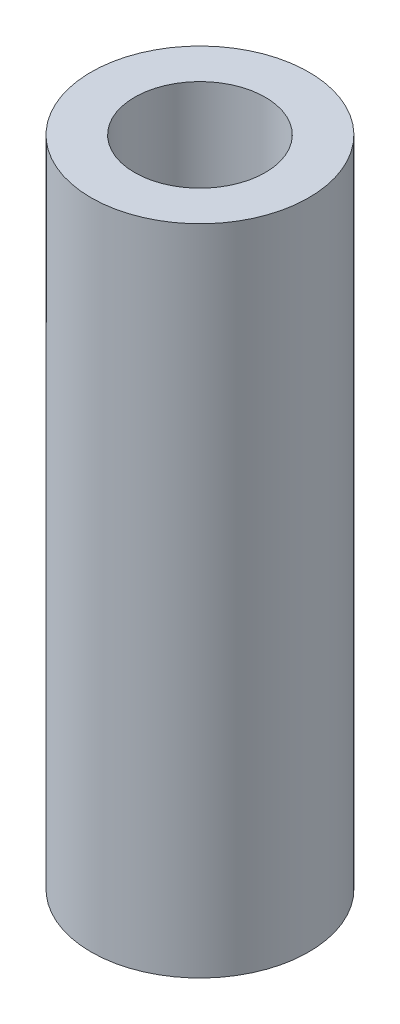
from build123d import *

# Parameters (mm, degrees)
SKIZZE1_R                       = 2
SKIZZE1_R_2                     = 1.2
AUFSATZ_LINEAR_AUSTRAGEN1_DEPTH = 6


with BuildPart() as part:
    # Skizze1 → Aufsatz-Linear austragen1 (new body, symmetric)
    with BuildSketch(Plane(origin=(0, 0, 0), x_dir=(1, 0, 0), z_dir=(0, 1, 0))):
        Circle(SKIZZE1_R)
        Circle(SKIZZE1_R_2, mode=Mode.SUBTRACT)
    extrude(amount=AUFSATZ_LINEAR_AUSTRAGEN1_DEPTH, both=True)


solid = part.part
